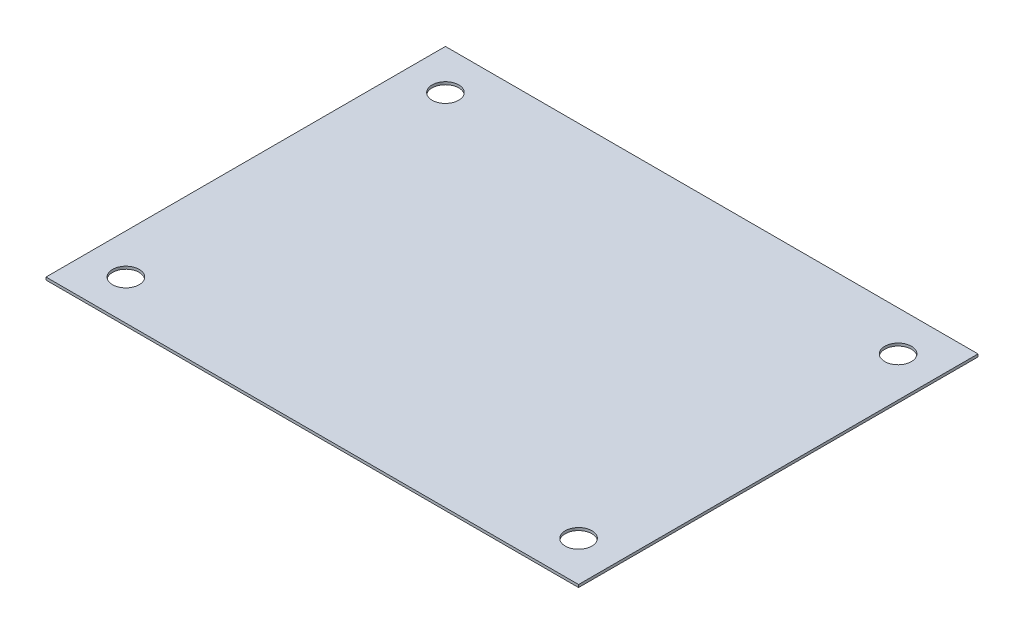
from build123d import *

# Parameters (mm, degrees)
SKETCH_1_W      = 400
SKETCH_1_H      = 300
SKETCH_1_R      = 10
EXTRUDE_1_DEPTH = 2


with BuildPart() as part:
    # 草图1 → 凸台-拉伸1 (new body)
    with BuildSketch(Plane(origin=(0, 0, 0), x_dir=(1, 0, 0), z_dir=(0, 1, 0))):
        Rectangle(SKETCH_1_W, SKETCH_1_H)
        with Locations((-170, 120)):
            Circle(SKETCH_1_R, mode=Mode.SUBTRACT)
        with Locations((-170, -120)):
            Circle(SKETCH_1_R, mode=Mode.SUBTRACT)
        with Locations((170, 120)):
            Circle(SKETCH_1_R, mode=Mode.SUBTRACT)
        with Locations((170, -120)):
            Circle(SKETCH_1_R, mode=Mode.SUBTRACT)
    extrude(amount=EXTRUDE_1_DEPTH)


solid = part.part
